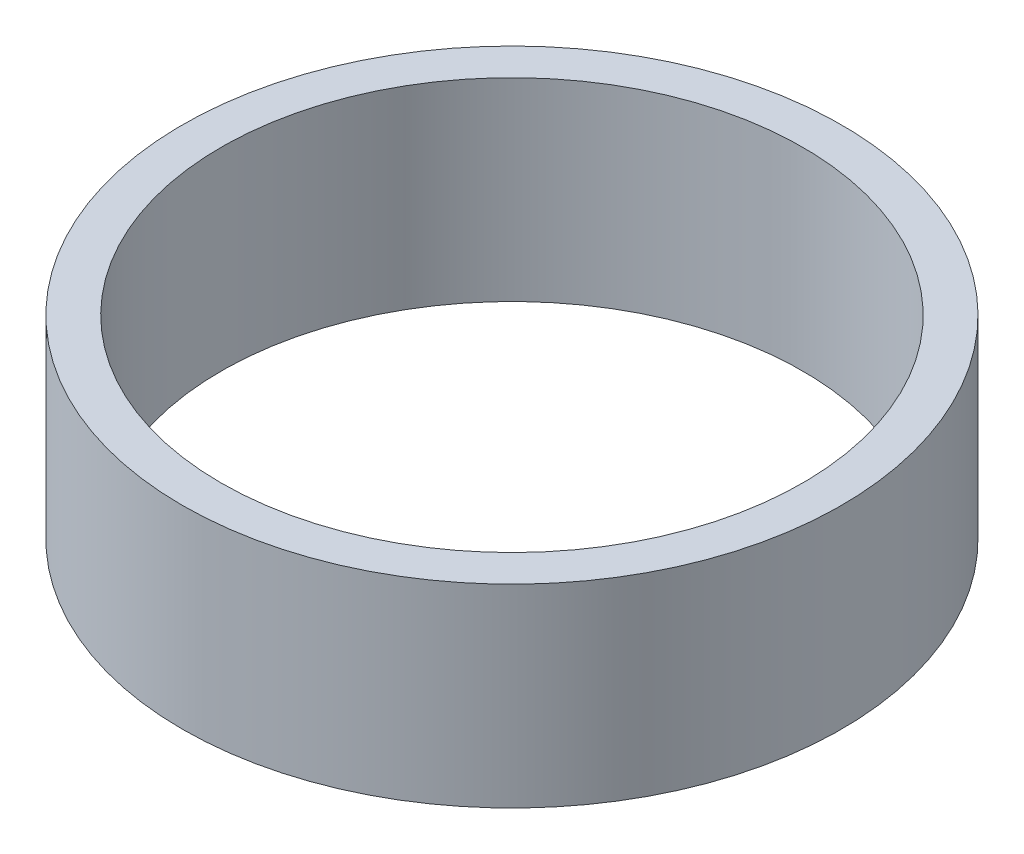
from build123d import *

# Parameters (mm, degrees)
SKETCH1_R           = 34
SKETCH1_R_2         = 30
BOSS_EXTRUDE1_DEPTH = 20


with BuildPart() as part:
    # Sketch1 → Boss-Extrude1 (new body)
    with BuildSketch(Plane(origin=(0, 0, 0), x_dir=(1, 0, 0), z_dir=(0, 1, 0))):
        Circle(SKETCH1_R)
        Circle(SKETCH1_R_2, mode=Mode.SUBTRACT)
    extrude(amount=BOSS_EXTRUDE1_DEPTH)


solid = part.part
